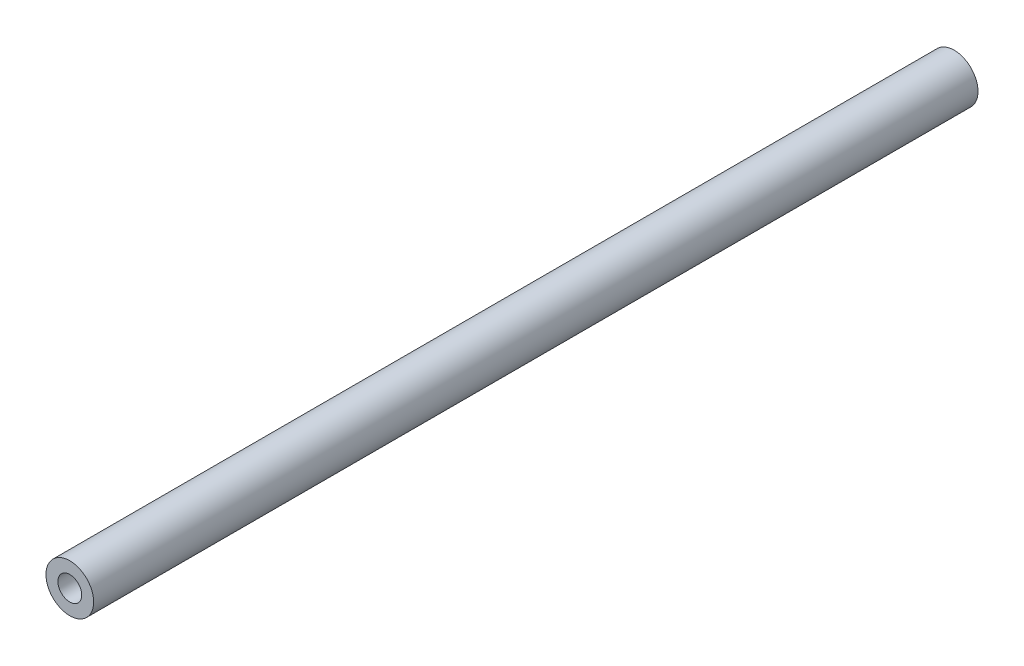
from build123d import *

# Parameters (mm, degrees)
SKETCH_1_R               = 2.5
EXTRUDE_1_DEPTH          = 46.35
M3X0_5_1_D               = 2.5
M3X0_5_1_DEPTH           = 8.5
M3X0_5_1_TIP             = 0.751075774
M3X0_5_1_ON_FACE_2_D     = 2.5
M3X0_5_1_ON_FACE_2_DEPTH = 8.5
M3X0_5_1_ON_FACE_2_TIP   = 0.751075774


with BuildPart() as part:
    # ｽｹｯﾁ1 → ﾎﾞｽ - 押し出し1 (new body, symmetric)
    with BuildSketch(Plane.XY):
        Circle(SKETCH_1_R)
    extrude(amount=EXTRUDE_1_DEPTH, both=True)

    # M3x0.5 ねじ穴1
    with Locations(Plane.XY.offset(46.35)):
        with Locations((0, 0)):
            Hole(M3X0_5_1_D / 2, depth=M3X0_5_1_DEPTH)
            with Locations((0, 0, -(M3X0_5_1_DEPTH + M3X0_5_1_TIP / 2))):  # 118° drill point
                Cone(0, M3X0_5_1_D / 2, M3X0_5_1_TIP, mode=Mode.SUBTRACT)

    # M3x0.5 ねじ穴1 on face 2
    with Locations(Plane(origin=(0, 0, -46.35), x_dir=(-1, 0, 0), z_dir=(0, 0, -1))):
        with Locations((0, 0)):
            Hole(M3X0_5_1_ON_FACE_2_D / 2, depth=M3X0_5_1_ON_FACE_2_DEPTH)
            with Locations((0, 0, -(M3X0_5_1_ON_FACE_2_DEPTH + M3X0_5_1_ON_FACE_2_TIP / 2))):  # 118° drill point
                Cone(0, M3X0_5_1_ON_FACE_2_D / 2, M3X0_5_1_ON_FACE_2_TIP, mode=Mode.SUBTRACT)


solid = part.part
